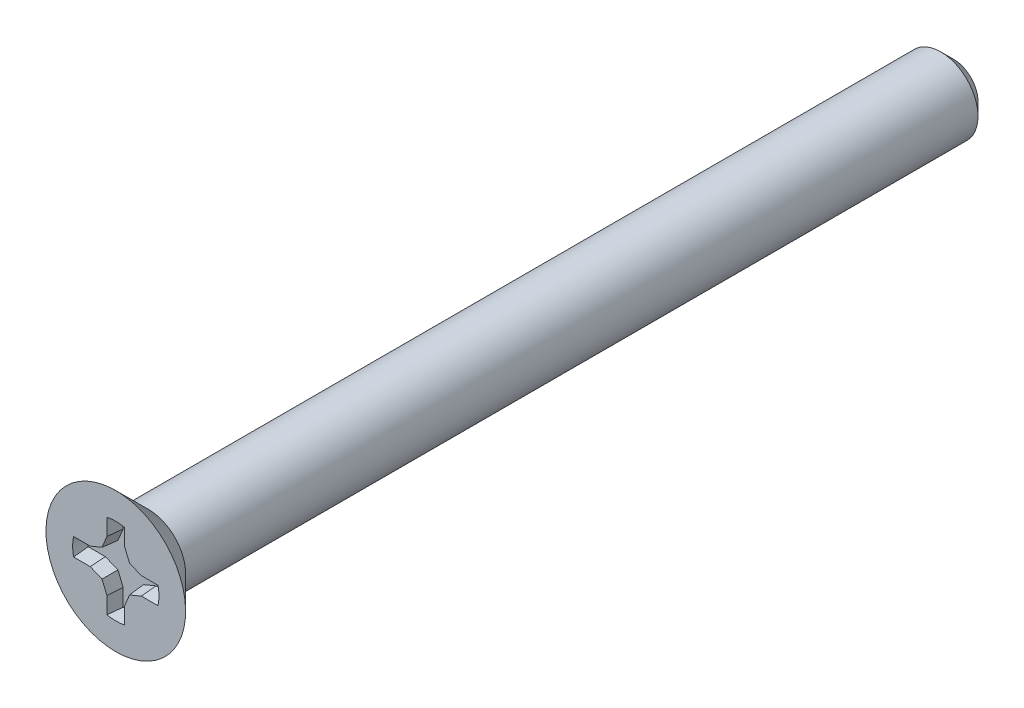
from build123d import *

# Parameters (mm, degrees)
CUT_EXTRUDE1_DEPTH  = 0.32
CIRPATTERN1_COUNT   = 4
DRAFT2_ANGLE        = 5
SKETCH8_R           = 0.8
BOSS_EXTRUDE1_DEPTH = 0.26
BOSS_EXTRUDE1_DRAFT = -45


with BuildPart() as part:
    # Sketch3 → Revolve1 (revolve)
    with BuildSketch(Plane(origin=(0, 0, 0), x_dir=(0, 0, -1), z_dir=(1, 0, 0)), mode=Mode.PRIVATE) as revolve1_sk:
        Polygon((-0.96, 0), (-0.96, 1.5), (-0.26, 0.8), (-0.26, 0), align=None)
    revolve(revolve1_sk.sketch.rotate(Axis((0, 0, 0.96), (0, 0, -1)), 180), axis=Axis((0, 0, 0.96), (0, 0, -1)))

    # Sketch5 → Revolve2 (revolve)
    with BuildSketch(Plane(origin=(0, 0, 0), x_dir=(0, 0, -1), z_dir=(1, 0, 0))):
        Polygon((17.04, 0), (-0.26, 0), (-0.26, 0.8), (16.7635, 0.8), (17.04, 0.5235), align=None)
    revolve(axis=Axis((0, 0, -17.04), (0, 0, 1)))

    # Sketch4 → Cut-Extrude1 (cut)
    with BuildSketch(Plane.XY.offset(0.96)):
        with BuildLine():
            Line((0, 0), (0.9271, 0))
            ThreePointArc((0.9271, 0), (0.92214099, 0.095762227), (0.907317012, 0.1905))
            Line((0.907317012, 0.1905), (0.548908506, 0.1905))
            Line((0.548908506, 0.1905), (0.295475421, 0.295475421))
            Line((0.295475421, 0.295475421), (0.1905, 0.548908506))
            Line((0.1905, 0.548908506), (0.1905, 0.907317012))
            ThreePointArc((0.1905, 0.907317012), (0.095762227, 0.92214099), (0, 0.9271))
            Line((0, 0.9271), (0, 0))
        make_face()
    cut_extrude1 = extrude(amount=-CUT_EXTRUDE1_DEPTH, mode=Mode.SUBTRACT)

    # CirPattern1: Cut-Extrude1 ×4 about axis
    cirpattern1_axis = Axis((0, 0, 0), (0, 0, 1))
    for i in range(1, CIRPATTERN1_COUNT):
        add(cut_extrude1.rotate(cirpattern1_axis, i * 360 / CIRPATTERN1_COUNT), mode=Mode.SUBTRACT)

    # Draft2
    draft2_faces = [part.faces().sort_by_distance(p)[0] for p in [
        (-0.728112759, 0.1905, 0.8),
        (-0.422191963, 0.24298771, 0.8),
        (-0.24298771, 0.422191963, 0.8),
        (-0.1905, 0.728112759, 0.8),
        (0.1905, 0.728112759, 0.8),
        (0.24298771, 0.422191963, 0.8),
        (0.422191963, 0.24298771, 0.8),
        (0.728112759, 0.1905, 0.8),
        (0.728112759, -0.1905, 0.8),
        (0.422191963, -0.24298771, 0.8),
        (0.24298771, -0.422191963, 0.8),
        (0.1905, -0.728112759, 0.8),
        (-0.1905, -0.728112759, 0.8),
        (-0.24298771, -0.422191963, 0.8),
        (-0.422191963, -0.24298771, 0.8),
        (-0.728112759, -0.1905, 0.8),
    ]]
    draft(draft2_faces, Plane(origin=(0, 0, 0.96), x_dir=(0, 1, 0), z_dir=(0, 0, 1)), DRAFT2_ANGLE)


with BuildPart() as body_2:
    # Split1: the piece on the far side of the plane
    add(part.part)
    split(bisect_by=Plane(origin=(0, 0, 0.26), x_dir=(0, -1, 0), z_dir=(0, 0, -1)), keep=Keep.BOTTOM)


with BuildPart() as part_1:
    add(part.part)

    # Split1
    split(bisect_by=Plane(origin=(0, 0, 0.26), x_dir=(0, -1, 0), z_dir=(0, 0, -1)), keep=Keep.TOP)


with BuildPart() as body_2_1:
    add(body_2.part)

    # Combine1: union part
    add(part_1.part)


with BuildPart() as boss_extrude1_tool:
    # Sketch8 → Boss-Extrude1 (with draft: the straight prism first)
    with BuildSketch(Plane.XY.offset(0.26)):
        with Locations(Location((0, 0, 0), (0, 0, 90))):
            Circle(SKETCH8_R)
    extrude(amount=-BOSS_EXTRUDE1_DEPTH)
    # Boss-Extrude1: the draft: its side faces are tilted about the plane it starts from
    boss_extrude1_sides = [boss_extrude1_tool.faces().sort_by_distance(p)[0] for p in [
        (0, -0.8, 0.13),
    ]]
    draft(boss_extrude1_sides, Plane.XY.offset(0.26), BOSS_EXTRUDE1_DRAFT)


with BuildPart() as body_2_2:
    add(body_2_1.part)

    # Boss-Extrude1: add boss_extrude1_tool
    add(boss_extrude1_tool.part)


solid = body_2_2.part
